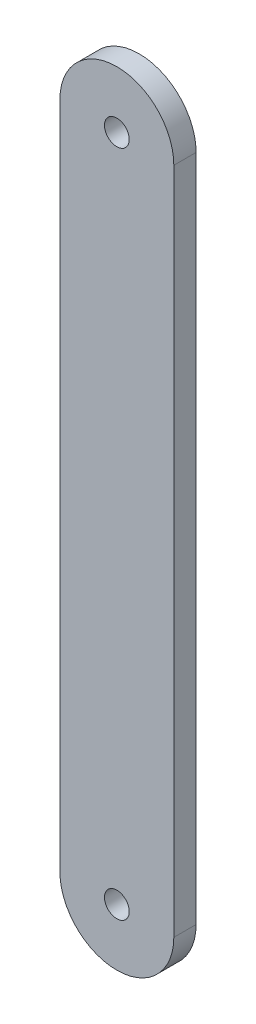
from build123d import *

# Parameters (mm, degrees)
SKETCH1_R           = 12.78
SKETCH1_R_2         = 2.78
BOSS_EXTRUDE1_DEPTH = 2.5


with BuildPart() as part:
    # Sketch1 → Boss-Extrude1 (new body, symmetric)
    with BuildSketch(Plane.XY):
        with BuildLine():
            ThreePointArc((12.78, 150), (0, 137.22), (-12.78, 150))
            Line((-12.78, 150), (-12.78, 0))
            ThreePointArc((-12.78, 0), (0, 12.78), (12.78, 0))
            Line((12.78, 0), (12.78, 150))
        make_face()
        with Locations((0, 150)):
            Circle(SKETCH1_R)
        with Locations((0, 150)):
            Circle(SKETCH1_R_2, mode=Mode.SUBTRACT)
        Circle(SKETCH1_R)
        Circle(SKETCH1_R_2, mode=Mode.SUBTRACT)
    extrude(amount=BOSS_EXTRUDE1_DEPTH, both=True)


solid = part.part
